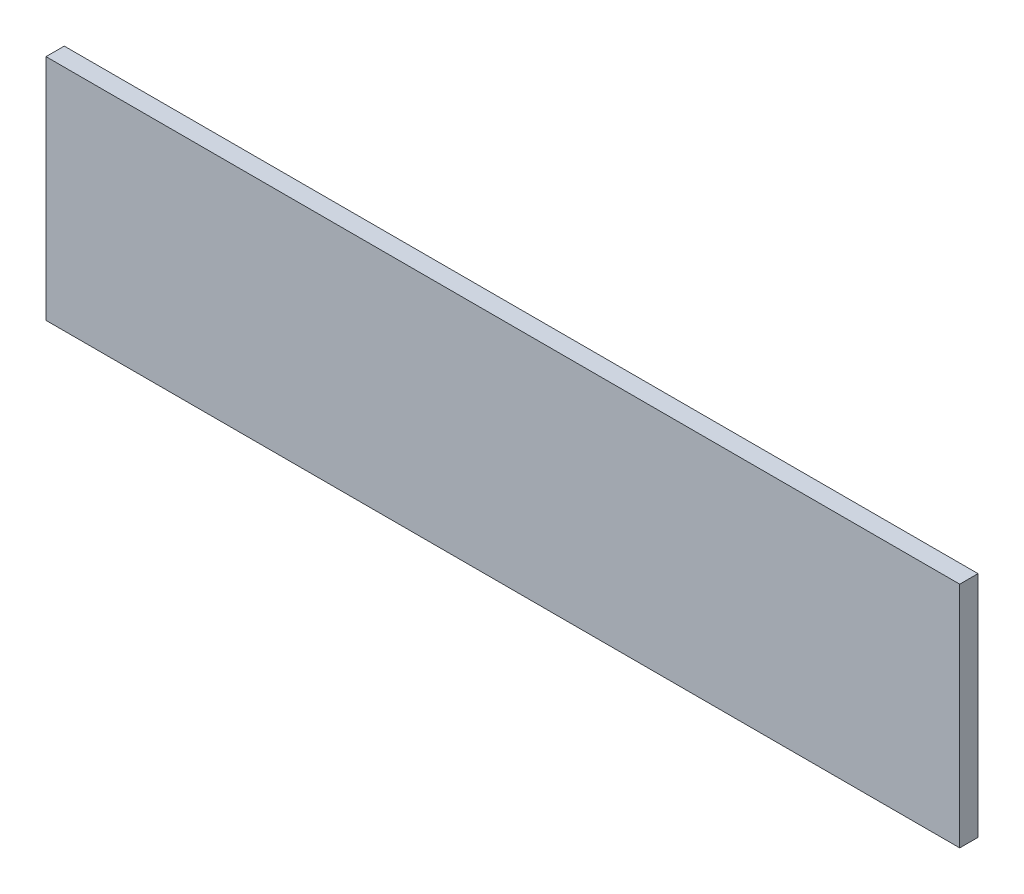
from build123d import *

# Parameters (mm, degrees)
SKETCH1_W           = 1000
SKETCH1_H           = 250
BOSS_EXTRUDE1_DEPTH = 20


with BuildPart() as part:
    # Sketch1 → Boss-Extrude1 (new body)
    with BuildSketch(Plane.XY):
        Rectangle(SKETCH1_W, SKETCH1_H)
    extrude(amount=BOSS_EXTRUDE1_DEPTH)


solid = part.part
